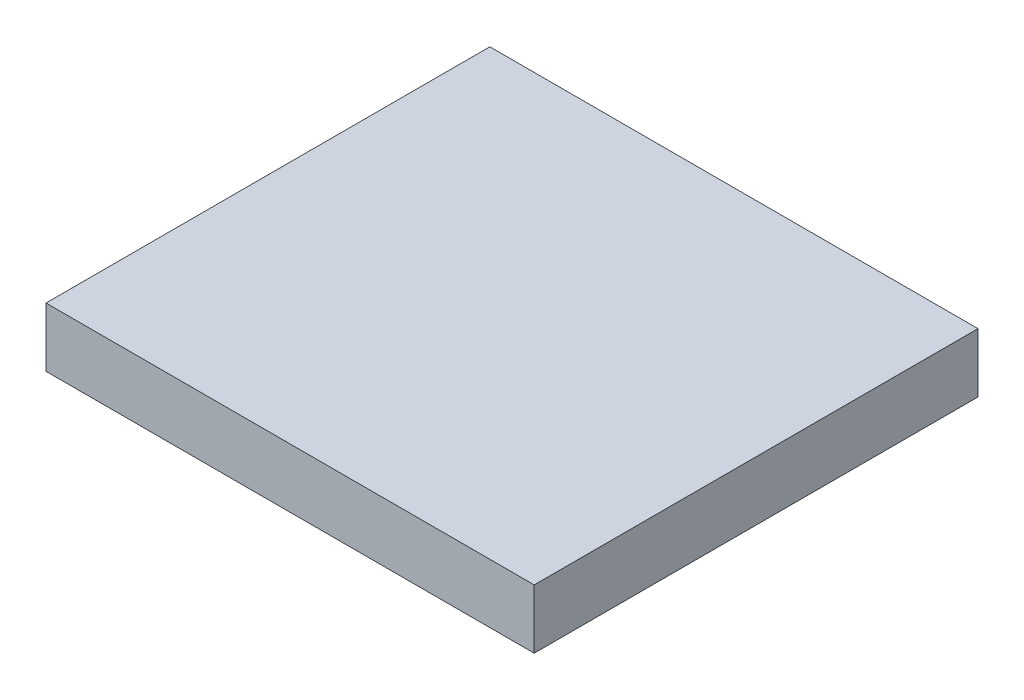
from build123d import *

# Parameters (mm, degrees)
SKETCH1_W                     = 41.91
SKETCH1_H                     = 38.1
BOSS_EXTRUDE1_DEPTH           = 5.08
TAP_DRILL_FOR_4_48_TAP1_D     = 2.3749
TAP_DRILL_FOR_4_48_TAP1_DEPTH = 10.16
TAP_DRILL_FOR_4_48_TAP1_TIP   = 0.713491942


with BuildPart() as part:
    # Sketch1 → Boss-Extrude1 (new body)
    with BuildSketch(Plane(origin=(0, 0, 0), x_dir=(1, 0, 0), z_dir=(0, 1, 0))):
        with Locations((-4.30427027, -8.5725)):
            Rectangle(SKETCH1_W, SKETCH1_H)
    extrude(amount=BOSS_EXTRUDE1_DEPTH)

    # Tap Drill for #4-48 Tap1
    with Locations(Plane.ZY.offset(25.25927027)):
        with Locations((-0.3175, 2.422722957), (22.5425, 2.422722957)):
            Hole(TAP_DRILL_FOR_4_48_TAP1_D / 2, depth=TAP_DRILL_FOR_4_48_TAP1_DEPTH)
            with Locations((0, 0, -(TAP_DRILL_FOR_4_48_TAP1_DEPTH + TAP_DRILL_FOR_4_48_TAP1_TIP / 2))):  # 118° drill point
                Cone(0, TAP_DRILL_FOR_4_48_TAP1_D / 2, TAP_DRILL_FOR_4_48_TAP1_TIP, mode=Mode.SUBTRACT)


solid = part.part
